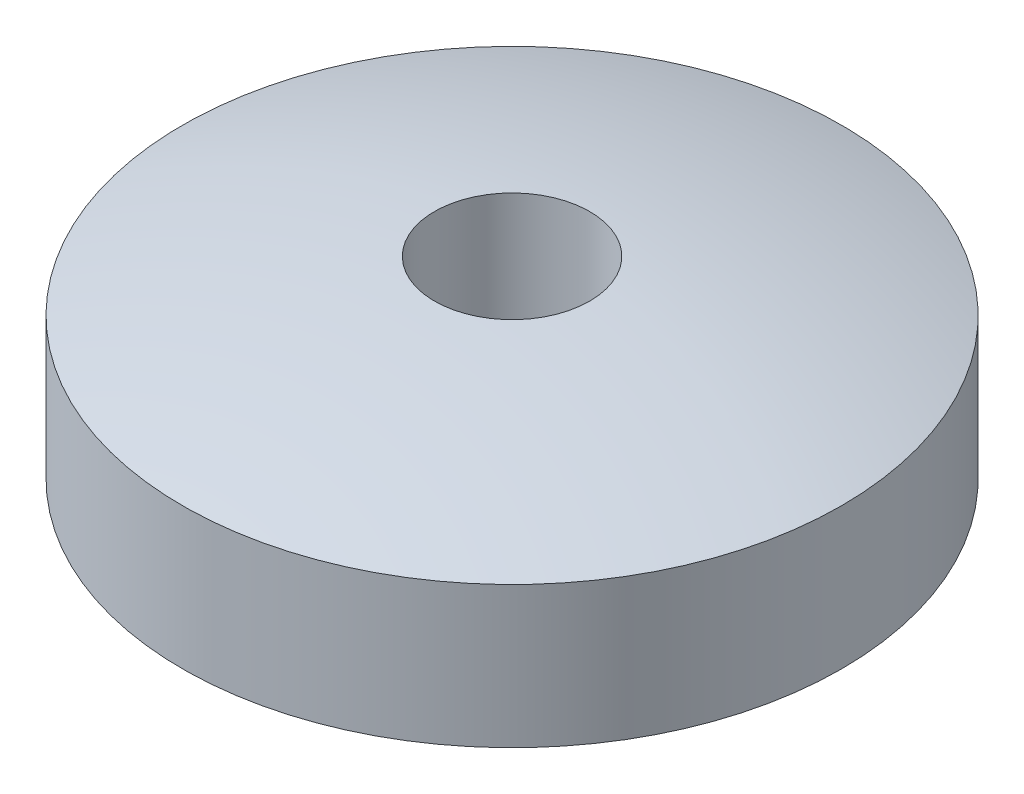
from build123d import *


with BuildPart() as part:
    # Sketch1 → Revolve1 (revolve)
    with BuildSketch(Plane.XY):
        with BuildLine():
            Line((-0.106, 0.262903905), (-0.106, 0.110199813))
            ThreePointArc((-0.106, 0.110199813), (-0.214691056, 0.068346612), (-0.309, 0))
            Line((-0.309, 0), (-0.45, 0))
            Line((-0.45, 0), (-0.45, 0.193))
            ThreePointArc((-0.45, 0.193), (-0.280188578, 0.238722033), (-0.106, 0.262903905))
        make_face()
    revolve(axis=Axis((0, -1000, 0), (0, 1, 0)))


solid = part.part
